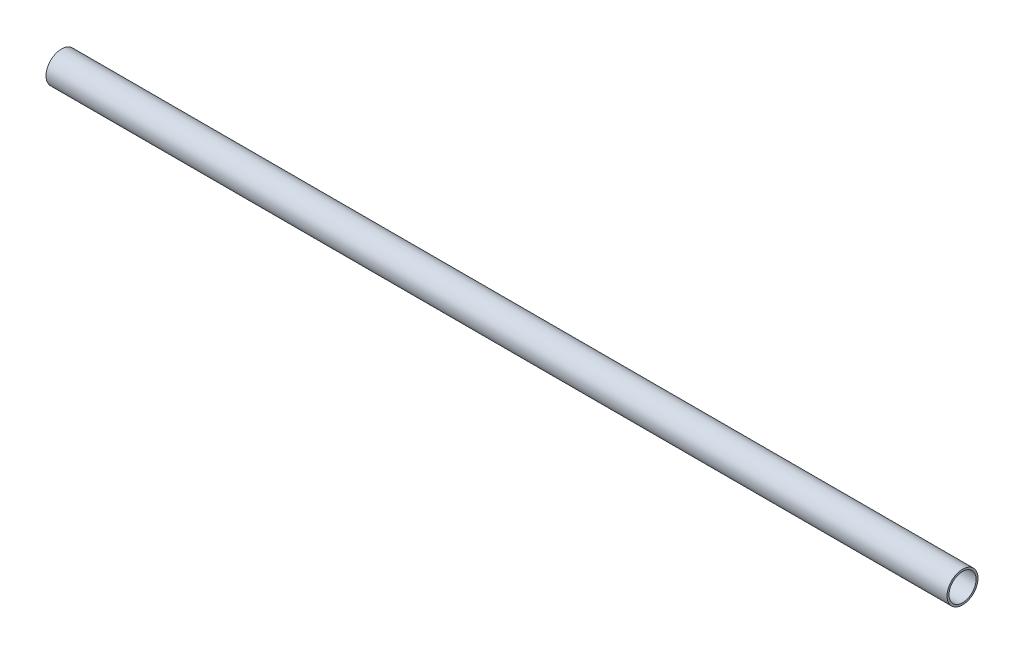
from build123d import *

# Parameters (mm, degrees)
SKIZZE1_W                       = 554
SKIZZE1_H                       = 1.2
SKIZZE2_W                       = 2
SKIZZE2_H                       = 0.603863108
AUFSATZ_LINEAR_AUSTRAGEN1_DEPTH = 10


with BuildPart() as part:
    # Skizze1 → Rotation1 (revolve)
    with BuildSketch(Plane.XY):
        with Locations((277, 8.925)):
            Rectangle(SKIZZE1_W, SKIZZE1_H)
    revolve(axis=Axis((0, 0, 0), (1, 0, 0)))

    # Skizze2 → Aufsatz-Linear austragen1 (add)
    with BuildSketch(Plane.ZY):
        with Locations((-7.687386884, 0)):
            Rectangle(SKIZZE2_W, SKIZZE2_H)
    extrude(amount=-AUFSATZ_LINEAR_AUSTRAGEN1_DEPTH)


solid = part.part
